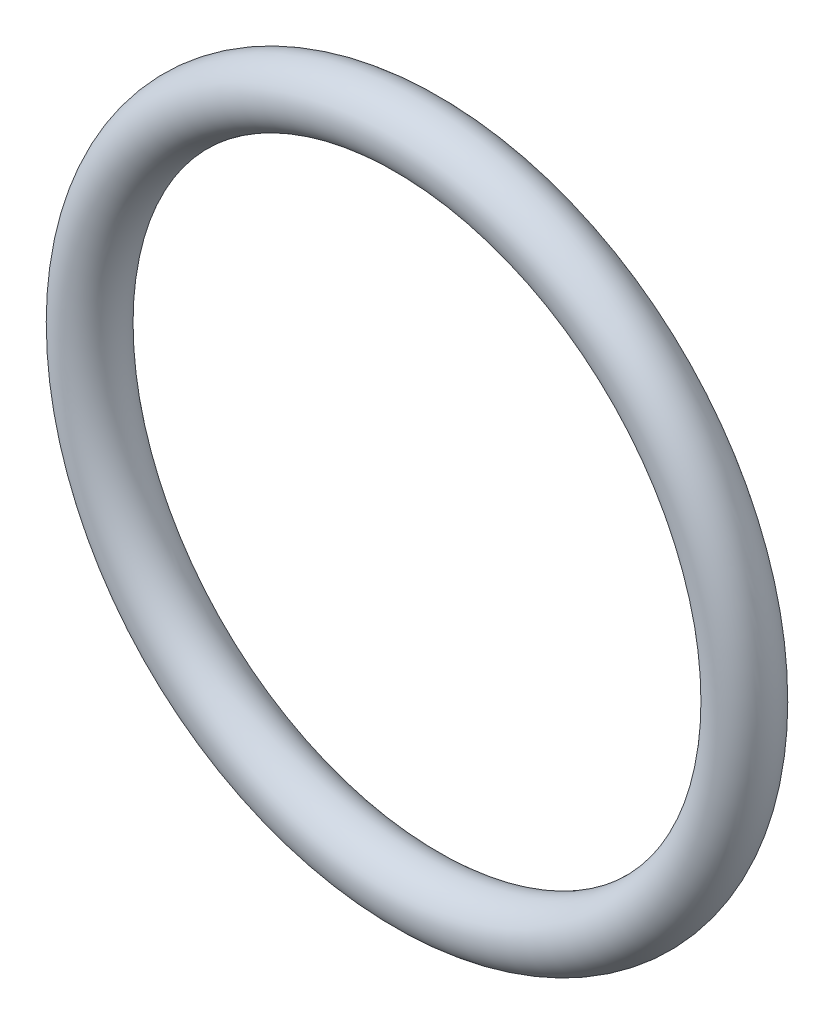
from build123d import *

# Parameters (mm, degrees)
SKETCH1_R = 0.889


with BuildPart() as part:
    # Sketch1 → Revolve1 (revolve)
    with BuildSketch(Plane(origin=(0, 0, 0), x_dir=(0, -1, 0), z_dir=(1, 0, 0))):
        with Locations((9.4742, 0)):
            Circle(SKETCH1_R)
    revolve(axis=Axis((0, 0, 0.889), (0, 0, -1)))


solid = part.part
